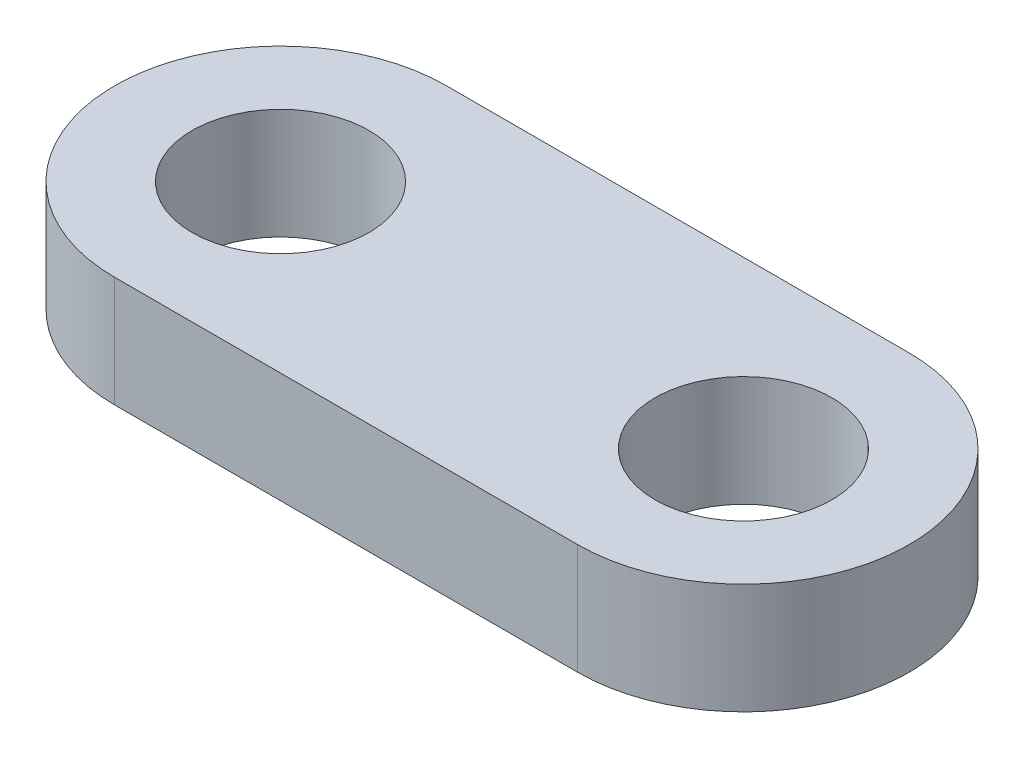
from build123d import *

# Parameters (mm, degrees)
SKETCH1_R           = 4
BOSS_EXTRUDE1_DEPTH = 5


with BuildPart() as part:
    # Sketch1 → Boss-Extrude1 (new body)
    with BuildSketch(Plane(origin=(0, 0, 0), x_dir=(1, 0, 0), z_dir=(0, 1, 0))):
        with BuildLine():
            Line((0, 7.5), (20.93, 7.5))
            ThreePointArc((20.93, 7.5), (28.43, 0), (20.93, -7.5))
            Line((20.93, -7.5), (0, -7.5))
            ThreePointArc((0, -7.5), (-7.5, 0), (0, 7.5))
        make_face()
        with Locations((20.93, 0)):
            Circle(SKETCH1_R, mode=Mode.SUBTRACT)
        Circle(SKETCH1_R, mode=Mode.SUBTRACT)
    extrude(amount=BOSS_EXTRUDE1_DEPTH)


solid = part.part
